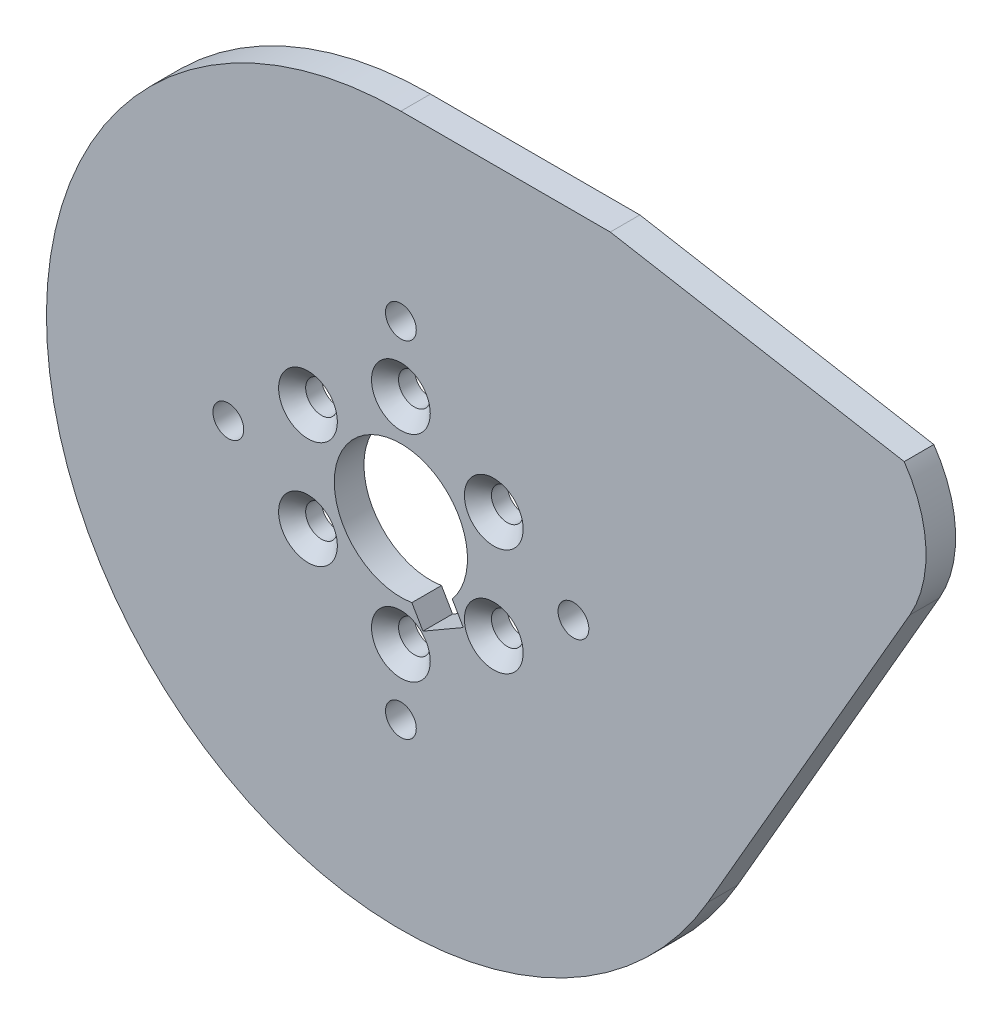
from build123d import *

# Parameters (mm, degrees)
BOSS_EXTRUDE1_DEPTH                               = 3.175
SKETCH4_W                                         = 7.1374
SKETCH4_H                                         = 3.175
F_4_CLEARANCE_HOLE1_D                             = 3.3
F_4_CLEARANCE_HOLE1_DEPTH                         = 3.175
CSK_FOR_4_FLAT_HEAD_MACHINE_SCREW_100_D           = 3.4
CSK_FOR_4_FLAT_HEAD_MACHINE_SCREW_100_DEPTH       = 3.175
CSK_FOR_4_FLAT_HEAD_MACHINE_SCREW_100_CSINK_D     = 6.3
CSK_FOR_4_FLAT_HEAD_MACHINE_SCREW_100_CSINK_ANGLE = 90
CUT_EXTRUDE1_DEPTH                                = 4.175


with BuildPart() as part:
    # Sketch1 → Boss-Extrude1 (new body)
    with BuildSketch(Plane.XY.offset(3.175)):
        with BuildLine():
            Line((53.959502015, 32.443258315), (22.445653919, 38))
            Line((22.445653919, 38), (0, 38))
            ThreePointArc((0, 38), (-32.908965344, -19), (32.908965344, -19))
            Line((32.908965344, -19), (54.559600438, 18.5))
            ThreePointArc((54.559600438, 18.5), (56.289246799, 25.558984429), (53.959502015, 32.443258315))
        make_face()
    extrude(amount=-BOSS_EXTRUDE1_DEPTH)

    # Sketch4 → Cut-Revolve1 (revolve, cut)
    with BuildSketch(Plane.XZ):
        with Locations((3.5687, 1.5875)):
            Rectangle(SKETCH4_W, SKETCH4_H)
    revolve(axis=Axis((0, 0, 3.175), (0, 0, -1)), mode=Mode.SUBTRACT)

    # #4 Clearance Hole1
    with Locations(Plane.XY.offset(3.175)):
        with Locations((18.5, 0), (0, -18.5), (-18.5, 0), (0, 18.5)):
            Hole(F_4_CLEARANCE_HOLE1_D / 2, depth=F_4_CLEARANCE_HOLE1_DEPTH)

    # CSK for #4 Flat Head Machine Screw (100)1
    with Locations(Plane.XY.offset(3.175)):
        with Locations((-9.959292144, 5.75), (-9.959292144, -5.75), (0, -11.5), (9.959292144, -5.75), (9.959292144, 5.75), (0, 11.5)):
            CounterSinkHole(CSK_FOR_4_FLAT_HEAD_MACHINE_SCREW_100_D / 2, CSK_FOR_4_FLAT_HEAD_MACHINE_SCREW_100_CSINK_D / 2, depth=CSK_FOR_4_FLAT_HEAD_MACHINE_SCREW_100_DEPTH, counter_sink_angle=CSK_FOR_4_FLAT_HEAD_MACHINE_SCREW_100_CSINK_ANGLE)

    # Sketch9 → Cut-Extrude1 (cut, through all)
    with BuildSketch(Plane(origin=(0, 0, 0), x_dir=(-1, 0, 0), z_dir=(0, 0, -1))):
        Polygon((-2.364186438, -9.09489103), (-6.694313457, -6.59489103), (-5.439804269, -4.422017377), (-1.10967725, -6.922017377), align=None)
    extrude(amount=-CUT_EXTRUDE1_DEPTH, mode=Mode.SUBTRACT)


solid = part.part
